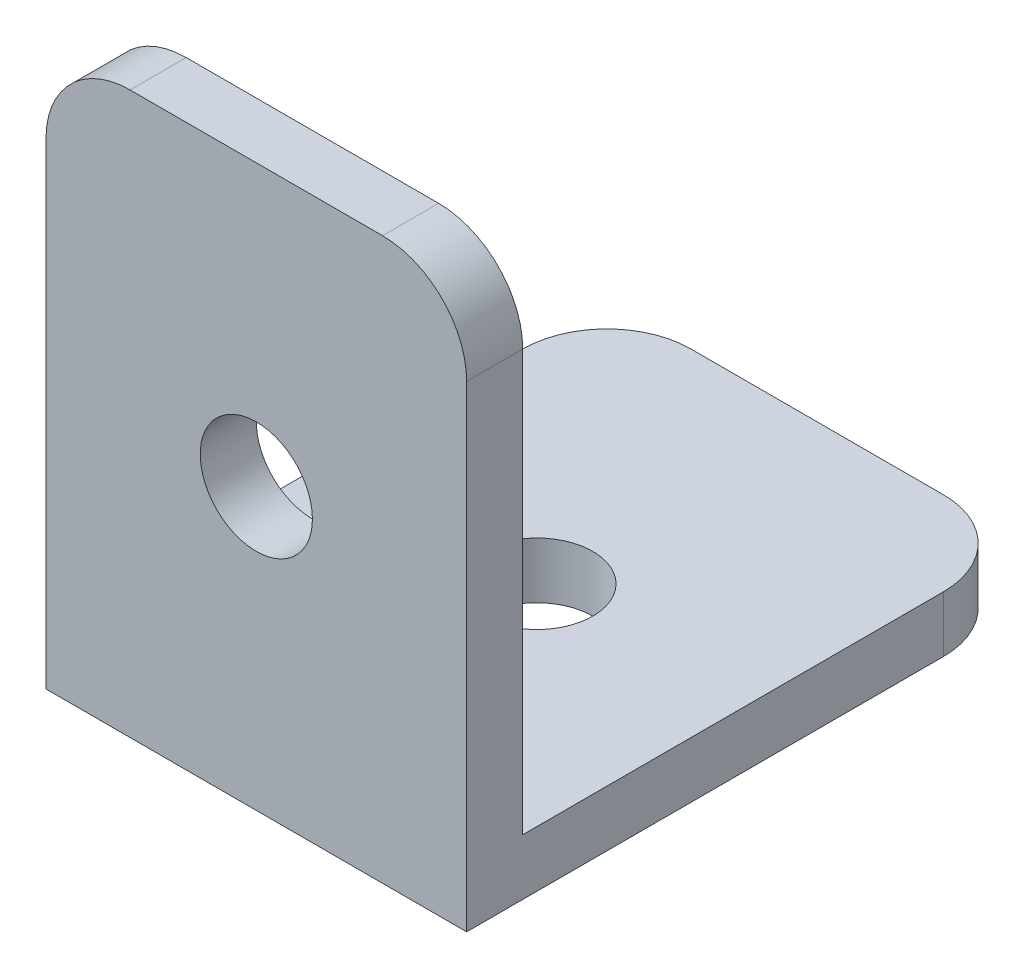
from build123d import *

# Parameters (mm, degrees)
SKETCH1_R           = 2
BOSS_EXTRUDE1_DEPTH = 2
SKETCH2_R           = 2
SKETCH2_W           = 15
SKETCH2_H           = 2
BOSS_EXTRUDE2_DEPTH = 2


with BuildPart() as part:
    # Sketch1 → Boss-Extrude1 (new body)
    with BuildSketch(Plane(origin=(0, 0, 0), x_dir=(1, 0, 0), z_dir=(0, 1, 0))):
        with BuildLine():
            Line((0, 0), (0, 15))
            ThreePointArc((0, 15), (0.878679656, 17.121320344), (3, 18))
            Line((3, 18), (12, 18))
            ThreePointArc((12, 18), (14.121320344, 17.121320344), (15, 15))
            Line((15, 15), (15, 0))
            Line((15, 0), (0, 0))
        make_face()
        with Locations((7.5, 8)):
            Circle(SKETCH1_R, mode=Mode.SUBTRACT)
    extrude(amount=BOSS_EXTRUDE1_DEPTH)

    # Sketch2 → Boss-Extrude2 (add)
    with BuildSketch(Plane.XY):
        with BuildLine():
            Line((0, 17), (0, 2))
            Line((0, 2), (15, 2))
            Line((15, 2), (15, 17))
            ThreePointArc((15, 17), (14.121320344, 19.121320344), (12, 20))
            Line((12, 20), (3, 20))
            ThreePointArc((3, 20), (0.878679656, 19.121320344), (0, 17))
        make_face()
        with Locations((7.5, 10)):
            Circle(SKETCH2_R, mode=Mode.SUBTRACT)
        with Locations((7.5, 1)):
            Rectangle(SKETCH2_W, SKETCH2_H)
    extrude(amount=BOSS_EXTRUDE2_DEPTH)


solid = part.part
